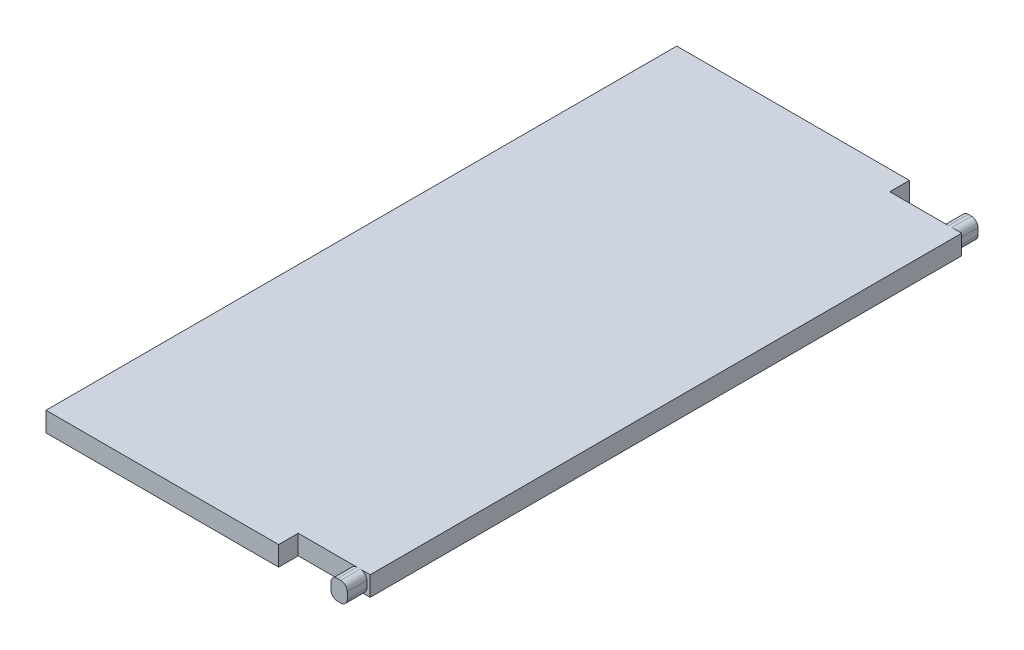
from build123d import *

# Parameters (mm, degrees)
SKETCH1_W               = 63.85
SKETCH1_H               = 96.52
BOSS_EXTRUDE1_DEPTH     = 3
SKETCH5_W               = 8
SKETCH5_H               = 3
CUT_EXTRUDE3_DEPTH      = 3
CUT_EXTRUDE6_DEPTH      = 1
CUT_EXTRUDE6_DEPTH_BACK = 3
SKETCH21_W              = 0.5
SKETCH21_H              = 3
CUT_EXTRUDE11_DEPTH     = 3
FILLET17_R              = 1
FILLET18_R              = 1
SKETCH22_W              = 96.52
SKETCH22_H              = 3
CUT_EXTRUDE12_DEPTH     = 17.25


with BuildPart() as part:
    # Sketch1 → Boss-Extrude1 (new body)
    with BuildSketch(Plane(origin=(0, 0, 0), x_dir=(1, 0, 0), z_dir=(0, 1, 0))):
        Rectangle(SKETCH1_W, SKETCH1_H)
    extrude(amount=BOSS_EXTRUDE1_DEPTH)

    # Sketch5 → Cut-Extrude3 (cut)
    with BuildSketch(Plane.XY.offset(48.26)):
        with Locations((24.925, 1.5)):
            Rectangle(SKETCH5_W, SKETCH5_H)
    cut_extrude3 = extrude(amount=-CUT_EXTRUDE3_DEPTH, mode=Mode.SUBTRACT)

    # Sketch20 → Cut-Extrude6 (cut, two sides)
    with BuildSketch(Plane.XY.offset(48.26)) as cut_extrude6_sk:
        Polygon((31.425, 139.841988316), (31.425, 3), (31.425, 0), (31.425, -136.841988316), (305.108976632, -136.841988316), (305.108976632, 139.841988316), align=None)
    extrude(amount=CUT_EXTRUDE6_DEPTH, mode=Mode.SUBTRACT)
    extrude(cut_extrude6_sk.sketch, amount=-CUT_EXTRUDE6_DEPTH_BACK, mode=Mode.SUBTRACT)

    # Mirror1: Cut-Extrude3 across plane
    add(cut_extrude3.mirror(Plane.XY), mode=Mode.SUBTRACT)

    # Sketch21 → Cut-Extrude11 (cut)
    with BuildSketch(Plane(origin=(0, 0, -48.26), x_dir=(-1, 0, 0), z_dir=(0, 0, -1))):
        with Locations((-31.675, 1.5)):
            Rectangle(SKETCH21_W, SKETCH21_H)
    extrude(amount=-CUT_EXTRUDE11_DEPTH, mode=Mode.SUBTRACT)

    # Fillet17
    fillet17_edges = [part.edges().sort_by_distance(p)[0] for p in [
        (28.925, 3, 46.76),
        (28.925, 0, 46.76),
        (31.425, 3, 46.76),
        (31.425, 0, 46.76),
    ]]
    fillet(fillet17_edges, radius=FILLET17_R)

    # Fillet18
    fillet18_edges = [part.edges().sort_by_distance(p)[0] for p in [
        (28.925, 3, -46.76),
        (28.925, 0, -46.76),
        (31.425, 3, -46.76),
        (31.425, 0, -46.76),
    ]]
    fillet(fillet18_edges, radius=FILLET18_R)

    # Sketch22 → Cut-Extrude12 (cut)
    with BuildSketch(Plane.ZY.offset(31.925)):
        with Locations((0, 1.5)):
            Rectangle(SKETCH22_W, SKETCH22_H)
    extrude(amount=-CUT_EXTRUDE12_DEPTH, mode=Mode.SUBTRACT)


solid = part.part
